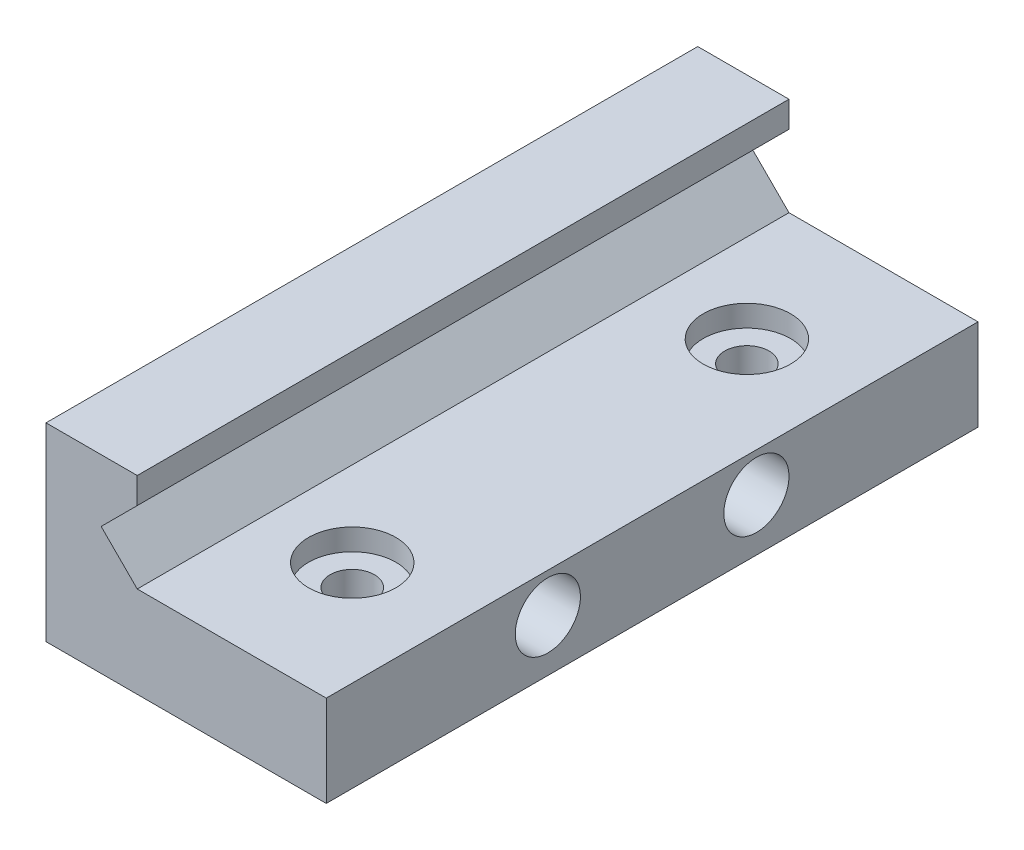
from build123d import *

# Parameters (mm, degrees)
BOSS_EXTRUDE1_DEPTH             = 50
CUT_EXTRUDE1_REACH              = 23.5
SKETCH3_R                       = 2.5
CBORE_FOR_M3_SBHCS1_D           = 3.4
CBORE_FOR_M3_SBHCS1_CBORE_D     = 6.7
CBORE_FOR_M3_SBHCS1_CBORE_DEPTH = 1.65


with BuildPart() as part:
    # Sketch2 → Boss-Extrude1 (new body)
    with BuildSketch(Plane.XY):
        Polygon((-15.713485752, 63.637116303), (-18.483485752, 60.867117128), (-15.713485752, 58.097116303), (-1.213485752, 58.097116303), (-1.213485752, 51.097116303), (-22.713485752, 51.097116303), (-22.713485752, 65.637116303), (-15.713485752, 65.637116303), align=None)
    extrude(amount=BOSS_EXTRUDE1_DEPTH)

    # Sketch3 → Cut-Extrude1 (cut, up to next)
    with BuildSketch(Plane.ZY.offset(22.713485752), mode=Mode.PRIVATE) as cut_extrude1_sk1:
        with Locations((17, 55.097116303)):
            Circle(SKETCH3_R)
    cut_extrude1_tool1 = extrude(cut_extrude1_sk1.sketch, amount=-CUT_EXTRUDE1_REACH, mode=Mode.PRIVATE) & part.part
    add(cut_extrude1_tool1.solids().sort_by_distance((-22.713486, 55.097116, 17))[0], mode=Mode.SUBTRACT)
    # Sketch3 → Cut-Extrude1 (cut, up to next)
    with BuildSketch(Plane.ZY.offset(22.713485752), mode=Mode.PRIVATE) as cut_extrude1_sk2:
        with Locations((33, 55.097116303)):
            Circle(SKETCH3_R)
    cut_extrude1_tool2 = extrude(cut_extrude1_sk2.sketch, amount=-CUT_EXTRUDE1_REACH, mode=Mode.PRIVATE) & part.part
    add(cut_extrude1_tool2.solids().sort_by_distance((-22.713486, 55.097116, 33))[0], mode=Mode.SUBTRACT)

    # CBORE for M3 SBHCS1 (through all)
    with Locations(Plane(origin=(0, 58.097116303, 0), x_dir=(1, 0, 0), z_dir=(0, 1, 0))):
        with Locations((-9.219799779, -40), (-8.943485752, -10)):
            CounterBoreHole(CBORE_FOR_M3_SBHCS1_D / 2, CBORE_FOR_M3_SBHCS1_CBORE_D / 2, CBORE_FOR_M3_SBHCS1_CBORE_DEPTH)


solid = part.part
